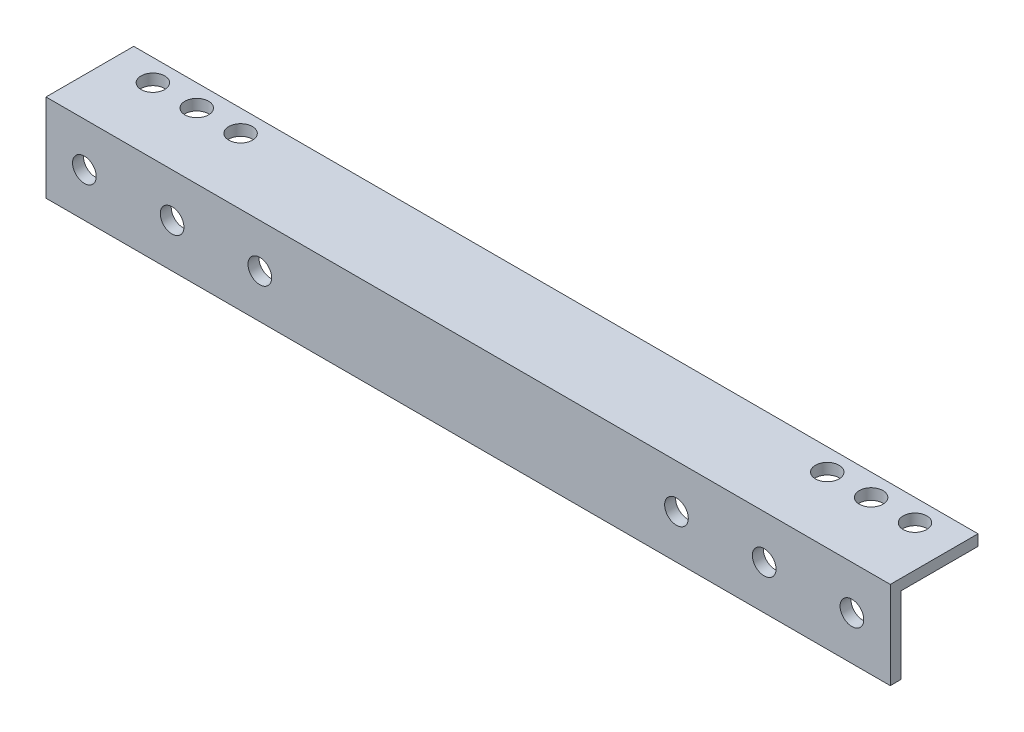
from build123d import *

# Parameters (mm, degrees)
BOSS_EXTRUDE1_DEPTH = 244.475
SKETCH2_R           = 3.429
CUT_EXTRUDE1_DEPTH  = 3.175
SKETCH3_R           = 3.429
CUT_EXTRUDE2_DEPTH  = 3.175


with BuildPart() as part:
    # Sketch1 → Boss-Extrude1 (new body)
    with BuildSketch(Plane(origin=(0, 0, 0), x_dir=(0, 0, -1), z_dir=(1, 0, 0))):
        Polygon((0, 0), (25.4, 0), (25.4, -3.175), (3.175, -3.175), (3.175, -25.4), (0, -25.4), align=None)
    extrude(amount=BOSS_EXTRUDE1_DEPTH)

    # Sketch2 → Cut-Extrude1 (cut)
    with BuildSketch(Plane.XY):
        with Locations((11.1125, -12.7)):
            Circle(SKETCH2_R)
        with Locations((36.5125, -12.7)):
            Circle(SKETCH2_R)
        with Locations((61.9125, -12.7)):
            Circle(SKETCH2_R)
        with Locations((182.5625, -12.7)):
            Circle(SKETCH2_R)
        with Locations((207.9625, -12.7)):
            Circle(SKETCH2_R)
        with Locations((233.3625, -12.7)):
            Circle(SKETCH2_R)
    extrude(amount=-CUT_EXTRUDE1_DEPTH, mode=Mode.SUBTRACT)

    # Sketch3 → Cut-Extrude2 (cut)
    with BuildSketch(Plane(origin=(0, 0, 0), x_dir=(1, 0, 0), z_dir=(0, 1, 0))):
        with Locations((11.8999, 19.05)):
            Circle(SKETCH3_R)
        with Locations((24.5999, 19.05)):
            Circle(SKETCH3_R)
        with Locations((37.2999, 19.05)):
            Circle(SKETCH3_R)
        with Locations((207.1751, 19.05)):
            Circle(SKETCH3_R)
        with Locations((219.8751, 19.05)):
            Circle(SKETCH3_R)
        with Locations((232.5751, 19.05)):
            Circle(SKETCH3_R)
    extrude(amount=-CUT_EXTRUDE2_DEPTH, mode=Mode.SUBTRACT)


solid = part.part
